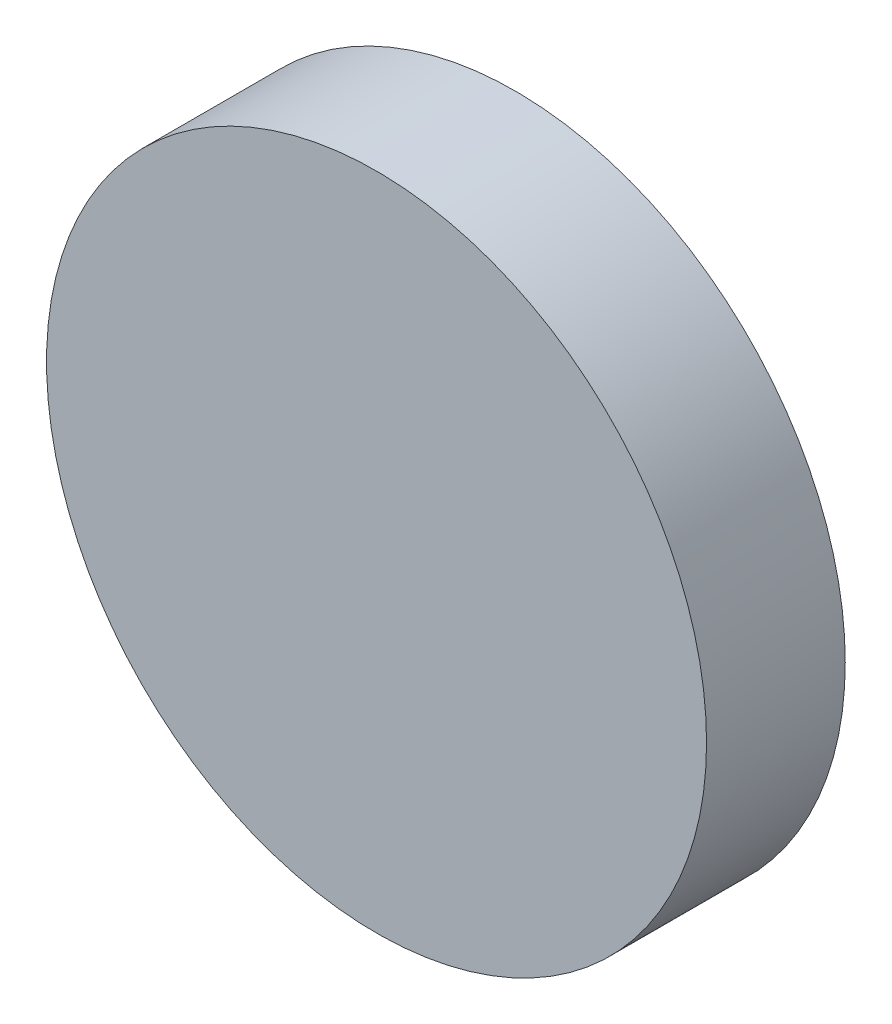
from build123d import *

# Parameters (mm, degrees)
SKETCH1_R           = 128
BOSS_EXTRUDE1_DEPTH = 53.8


with BuildPart() as part:
    # Sketch1 → Boss-Extrude1 (new body)
    with BuildSketch(Plane.XY):
        Circle(SKETCH1_R)
    extrude(amount=BOSS_EXTRUDE1_DEPTH)


solid = part.part
